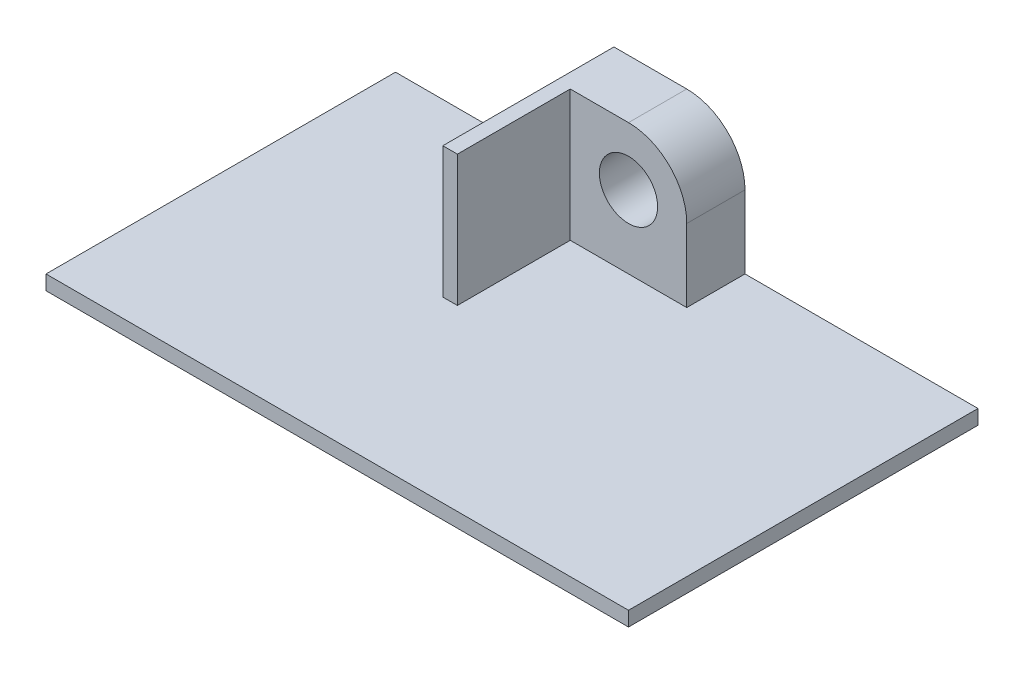
from build123d import *

# Parameters (mm, degrees)
SKETCH1_W           = 63.5
SKETCH1_H           = 1.5875
BOSS_EXTRUDE1_DEPTH = 38.1
SKETCH2_R           = 3.175
BOSS_EXTRUDE2_DEPTH = 6.35
SKETCH3_W           = 1.5875
SKETCH3_H           = 18.653125
BOSS_EXTRUDE3_DEPTH = 14.2875


with BuildPart() as part:
    # Sketch1 → Boss-Extrude1 (new body)
    with BuildSketch(Plane.XY):
        with Locations((31.75, 0.79375)):
            Rectangle(SKETCH1_W, SKETCH1_H)
    extrude(amount=BOSS_EXTRUDE1_DEPTH)

    # Sketch2 → Boss-Extrude2 (add)
    with BuildSketch(Plane(origin=(0, 0, 0), x_dir=(-1, 0, 0), z_dir=(0, 0, -1))):
        with BuildLine():
            Line((-38.1, 9.525), (-38.1, 1.5875))
            Line((-38.1, 1.5875), (-25.4, 1.5875))
            Line((-25.4, 1.5875), (-25.4, 9.525))
            Line((-25.4, 9.525), (-25.4, 15.875))
            Line((-25.4, 15.875), (-31.75, 15.875))
            ThreePointArc((-31.75, 15.875), (-36.240128061, 14.015128061), (-38.1, 9.525))
        make_face()
        with Locations((-31.75, 9.525)):
            Circle(SKETCH2_R, mode=Mode.SUBTRACT)
    extrude(amount=-BOSS_EXTRUDE2_DEPTH)

    # Sketch3 → Boss-Extrude3 (add)
    with BuildSketch(Plane(origin=(0, 1.5875, 0), x_dir=(1, 0, 0), z_dir=(0, 1, 0))):
        with Locations((24.60625, -9.3265625)):
            Rectangle(SKETCH3_W, SKETCH3_H)
    extrude(amount=BOSS_EXTRUDE3_DEPTH)


solid = part.part
